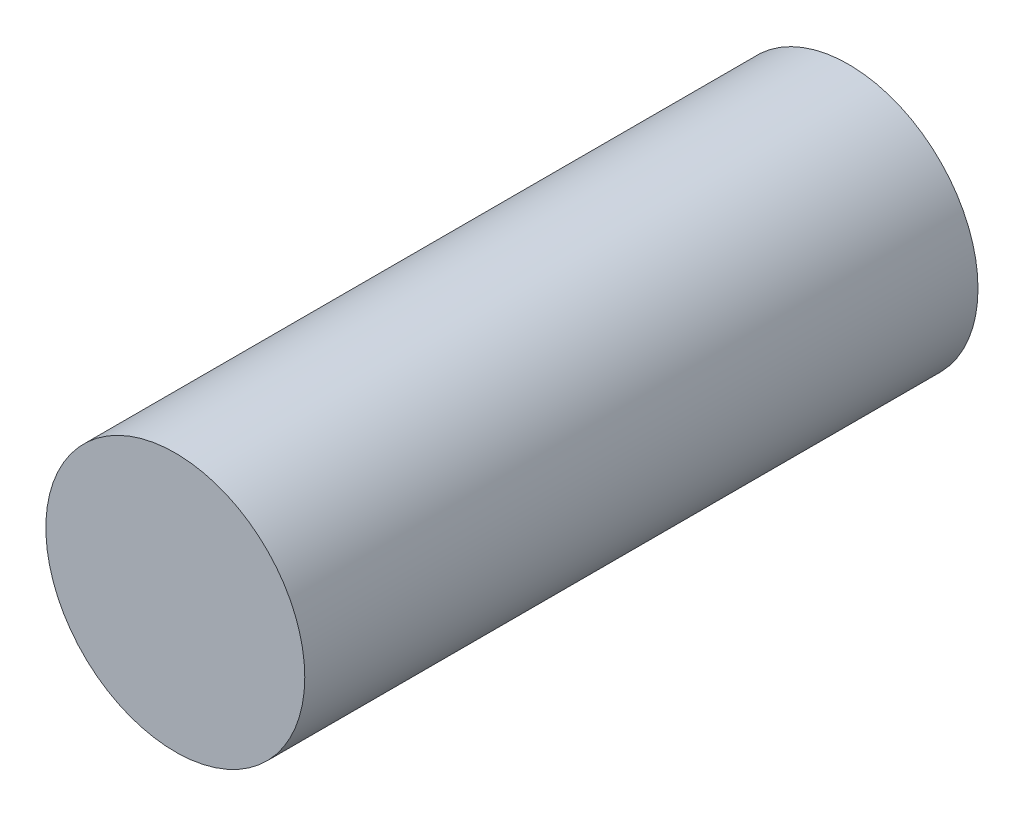
from build123d import *

# Parameters (mm, degrees)
SKETCH1_R           = 2.5
BOSS_EXTRUDE1_DEPTH = 13


with BuildPart() as part:
    # Sketch1 → Boss-Extrude1 (new body)
    with BuildSketch(Plane.XY):
        Circle(SKETCH1_R)
    extrude(amount=BOSS_EXTRUDE1_DEPTH)


solid = part.part
